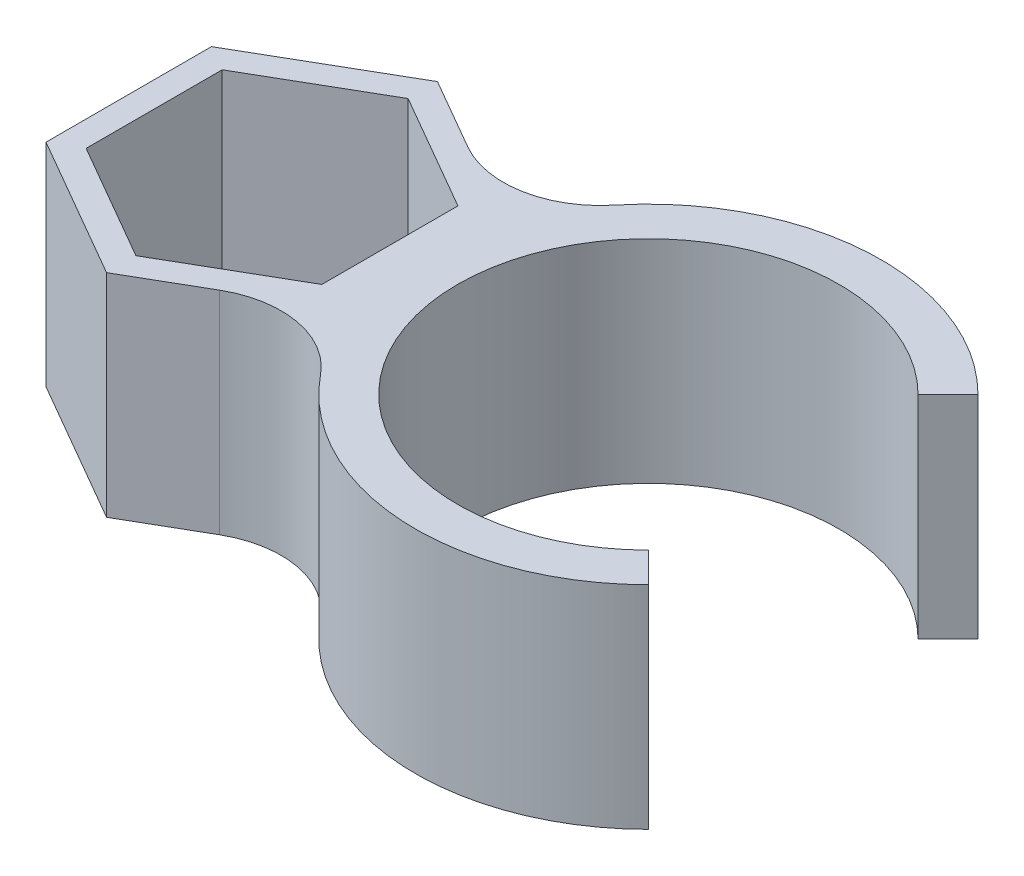
from build123d import *

# Parameters (mm, degrees)
BOSS_EXTRUDE1_DEPTH = 10


with BuildPart() as part:
    # Sketch1 → Boss-Extrude1 (new body)
    with BuildSketch(Plane(origin=(0, 0, 0), x_dir=(1, 0, 0), z_dir=(0, 1, 0))):
        Polygon((0, -7.808777861), (6.7626, -3.90438893), (6.7626, 3.90438893), (0, 7.808777861), (-6.7626, 3.90438893), (-6.7626, -3.90438893), align=None)
        Polygon((5.5626, -3.211568607), (5.5626, 3.211568607), (0, 6.423137215), (-5.5626, 3.211568607), (-5.5626, -3.211568607), (0, -6.423137215), align=None, mode=Mode.SUBTRACT)
        with BuildLine():
            ThreePointArc((9.224161182, -6.935060385), (7.396240301, -3.679481838), (6.7626, -2.8e-08))
            Line((6.7626, -2.8e-08), (6.7626, -3.90438893))
            Line((6.7626, -3.90438893), (3.3813, -5.856583396))
            ThreePointArc((3.3813, -5.856583396), (6.501441474, -5.319266604), (9.224161182, -6.935060385))
        make_face()
        with BuildLine():
            ThreePointArc((6.7626, -2.8e-08), (7.396240292, 3.679481812), (9.224161182, 6.935060385))
            ThreePointArc((9.224161182, 6.935060385), (6.501441474, 5.319266604), (3.3813, 5.856583396))
            Line((3.3813, 5.856583396), (6.7626, 3.90438893))
            Line((6.7626, 3.90438893), (6.7626, -2.8e-08))
        make_face()
        with BuildLine():
            Line((24.126561031, 6.363961031), (25.540774593, 7.778174593))
            ThreePointArc((25.540774593, 7.778174593), (6.7626, 0), (25.540774593, -7.778174593))
            Line((25.540774593, -7.778174593), (24.126561031, -6.363961031))
            ThreePointArc((24.126561031, -6.363961031), (8.7626, 0), (24.126561031, 6.363961031))
        make_face()
    extrude(amount=BOSS_EXTRUDE1_DEPTH)


solid = part.part
